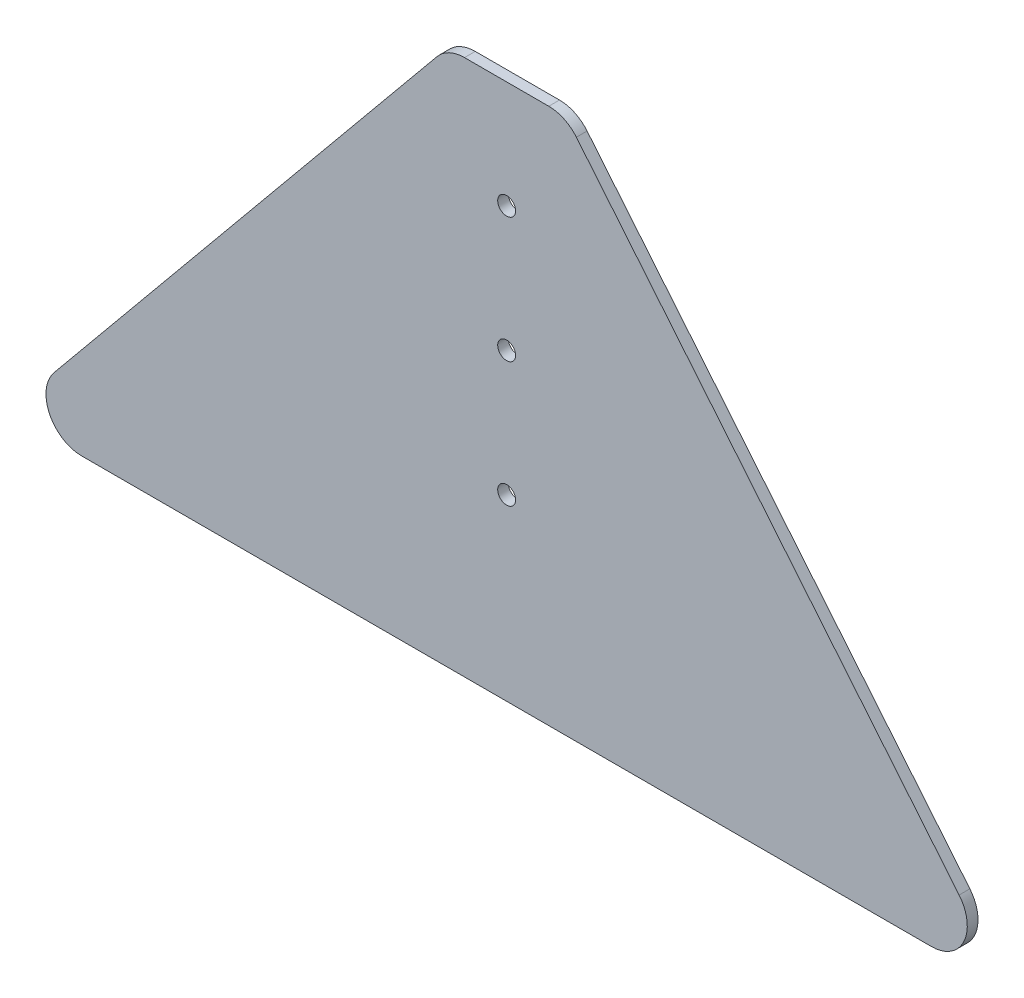
from build123d import *

# Parameters (mm, degrees)
SKETCH1_R           = 2.5
BOSS_EXTRUDE1_DEPTH = 3
FILLET1_R           = 10


with BuildPart() as part:
    # Sketch1 → Boss-Extrude1 (new body)
    with BuildSketch(Plane.XY):
        Polygon((0, 150), (-123.5, 0), (0, 0), (33, 0), (156.5, 0), (33, 150), align=None)
        with Locations((16.5, 85)):
            Circle(SKETCH1_R, mode=Mode.SUBTRACT)
        with Locations((16.5, 120)):
            Circle(SKETCH1_R, mode=Mode.SUBTRACT)
        with Locations((16.5, 50)):
            Circle(SKETCH1_R, mode=Mode.SUBTRACT)
    extrude(amount=BOSS_EXTRUDE1_DEPTH)

    # Fillet1
    fillet1_edges = [part.edges().sort_by_distance(p)[0] for p in [
        (-123.5, 0, 1.5),
        (0, 150, 1.5),
        (33, 150, 1.5),
        (156.5, 0, 1.5),
    ]]
    fillet(fillet1_edges, radius=FILLET1_R)


solid = part.part
